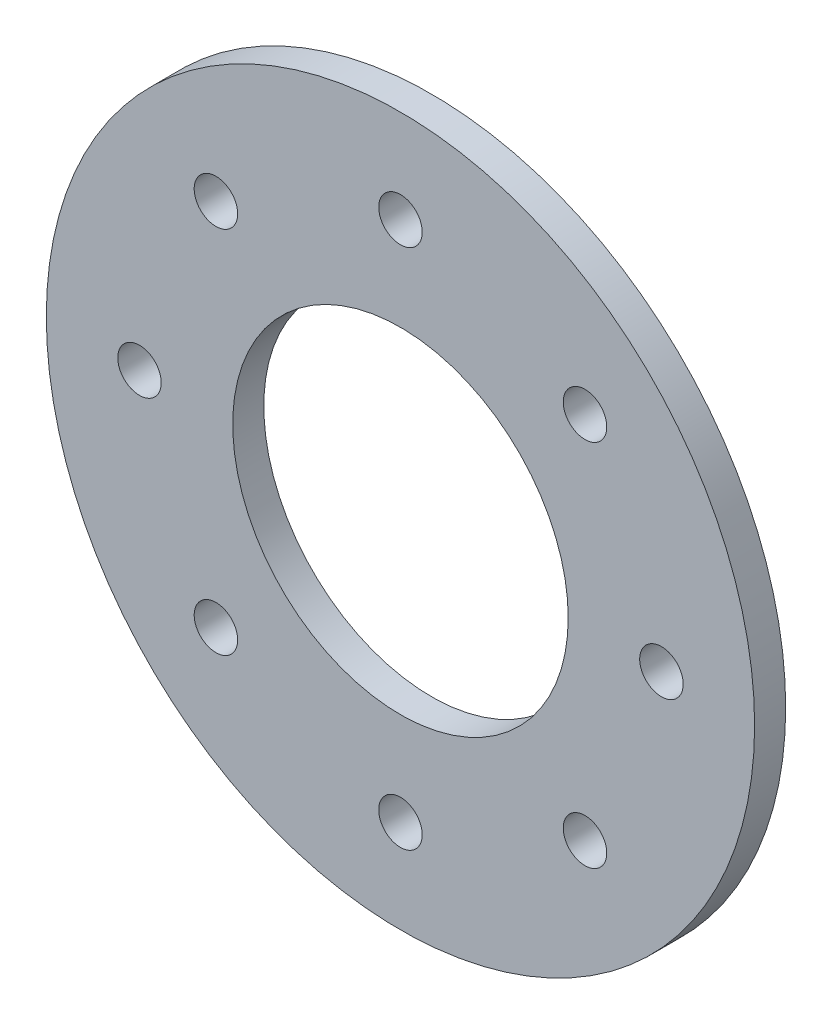
from build123d import *

# Parameters (mm, degrees)
SKETCH3_R           = 57
SKETCH3_R_2         = 26.999999975
SKETCH3_R_3         = 3.5
BOSS_EXTRUDE1_DEPTH = 5


with BuildPart() as part:
    # Sketch3 → Boss-Extrude1 (new body)
    with BuildSketch(Plane.XY):
        Circle(SKETCH3_R)
        Circle(SKETCH3_R_2, mode=Mode.SUBTRACT)
        with Locations((-42, 0)):
            Circle(SKETCH3_R_3, mode=Mode.SUBTRACT)
        with Locations((-29.69848481, 29.69848481)):
            Circle(SKETCH3_R_3, mode=Mode.SUBTRACT)
        with Locations((0, 42)):
            Circle(SKETCH3_R_3, mode=Mode.SUBTRACT)
        with Locations((29.69848481, 29.69848481)):
            Circle(SKETCH3_R_3, mode=Mode.SUBTRACT)
        with Locations((42, 0)):
            Circle(SKETCH3_R_3, mode=Mode.SUBTRACT)
        with Locations((29.69848481, -29.69848481)):
            Circle(SKETCH3_R_3, mode=Mode.SUBTRACT)
        with Locations((0, -42)):
            Circle(SKETCH3_R_3, mode=Mode.SUBTRACT)
        with Locations((-29.69848481, -29.69848481)):
            Circle(SKETCH3_R_3, mode=Mode.SUBTRACT)
    extrude(amount=BOSS_EXTRUDE1_DEPTH)


solid = part.part
